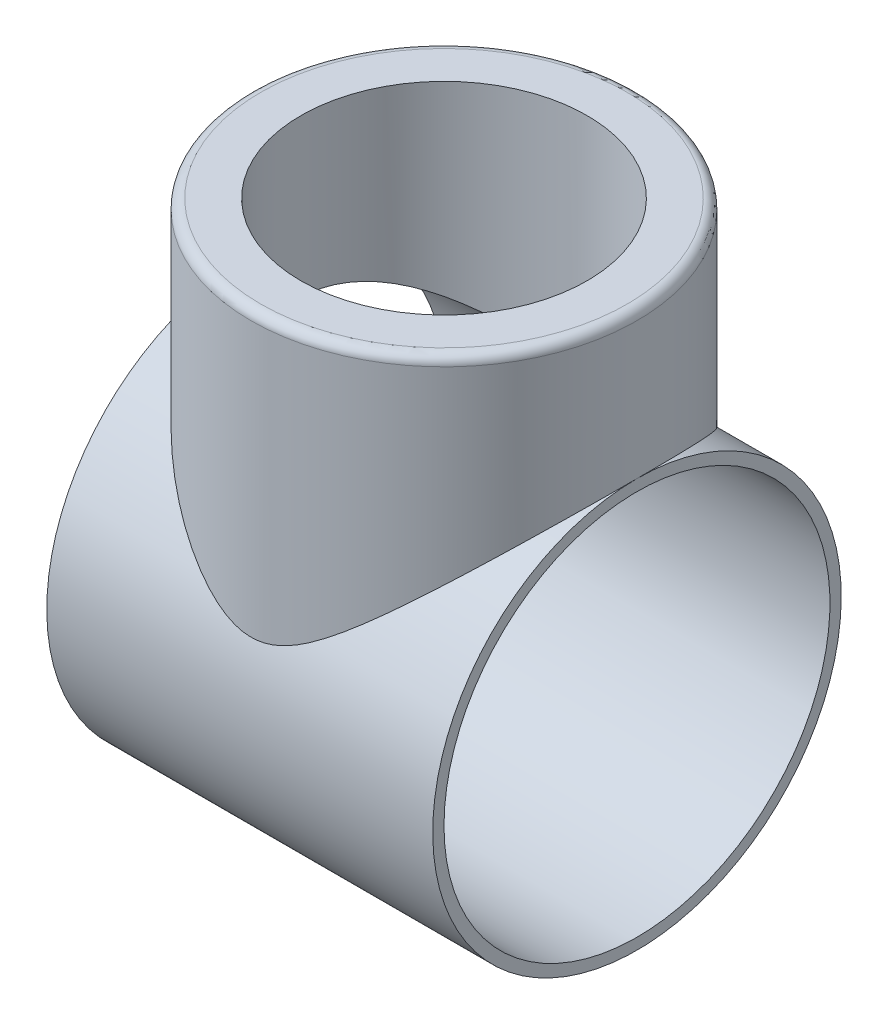
from build123d import *
from build123d.topology import SkipClean

# Parameters (mm, degrees)
SKETCH1_W                  = 120
SKETCH1_H                  = 63.5
SKETCH2_W                  = 60
SKETCH2_H                  = 88.209377114
HOLE1_D                    = 120
M80_CLEARANCE_HOLE1_REACH  = 195.361
M80_CLEARANCE_HOLE1_BORE_R = 44.5
FILLET1_R                  = 3


with BuildPart() as part:
    # Sketch1 → Revolve1 (revolve)
    with BuildSketch(Plane(origin=(0, 0, 0), x_dir=(-1, 0, 0), z_dir=(0, 0, -1)), mode=Mode.PRIVATE) as revolve1_sk:
        with Locations((0, 31.75)):
            Rectangle(SKETCH1_W, SKETCH1_H)
    revolve(revolve1_sk.sketch.rotate(Axis((60, 0, 0), (-1, 0, 0)), 270), axis=Axis((60, 0, 0), (-1, 0, 0)))

    # Sketch2 → Revolve2 (revolve)
    with SkipClean():  # the faces are left unmerged after this step: merging them gives an invalid solid
        with BuildSketch(Plane.XY, mode=Mode.PRIVATE) as revolve2_sk:
            with Locations((30, 64.895311443)):
                Rectangle(SKETCH2_W, SKETCH2_H)
        revolve(revolve2_sk.sketch.rotate(Axis((0, 109, 0), (0, -1, 0)), 270), axis=Axis((0, 109, 0), (0, -1, 0)))

    # Hole1 (through all)
    with Locations(Plane.ZY.offset(60)):
        with Locations((0, 0)):
            Hole(HOLE1_D / 2)

    # M80 Clearance Hole1 bore → M80 Clearance Hole1 (cut, up to next)
    with BuildSketch(Plane(origin=(0, 109, 0), x_dir=(1, 0, 0), z_dir=(0, 1, 0)), mode=Mode.PRIVATE) as m80_clearance_hole1_sk1:
        Circle(M80_CLEARANCE_HOLE1_BORE_R)
    m80_clearance_hole1_tool1 = extrude(m80_clearance_hole1_sk1.sketch, amount=-M80_CLEARANCE_HOLE1_REACH, mode=Mode.PRIVATE) & part.part
    add(m80_clearance_hole1_tool1.solids().sort_by_distance((0, 109, 0))[0], mode=Mode.SUBTRACT)

    # Fillet1
    fillet1_edges = [part.edges().sort_by_distance(p)[0] for p in [
        (0, 109, 60),
    ]]
    fillet(fillet1_edges, radius=FILLET1_R)


solid = part.part
